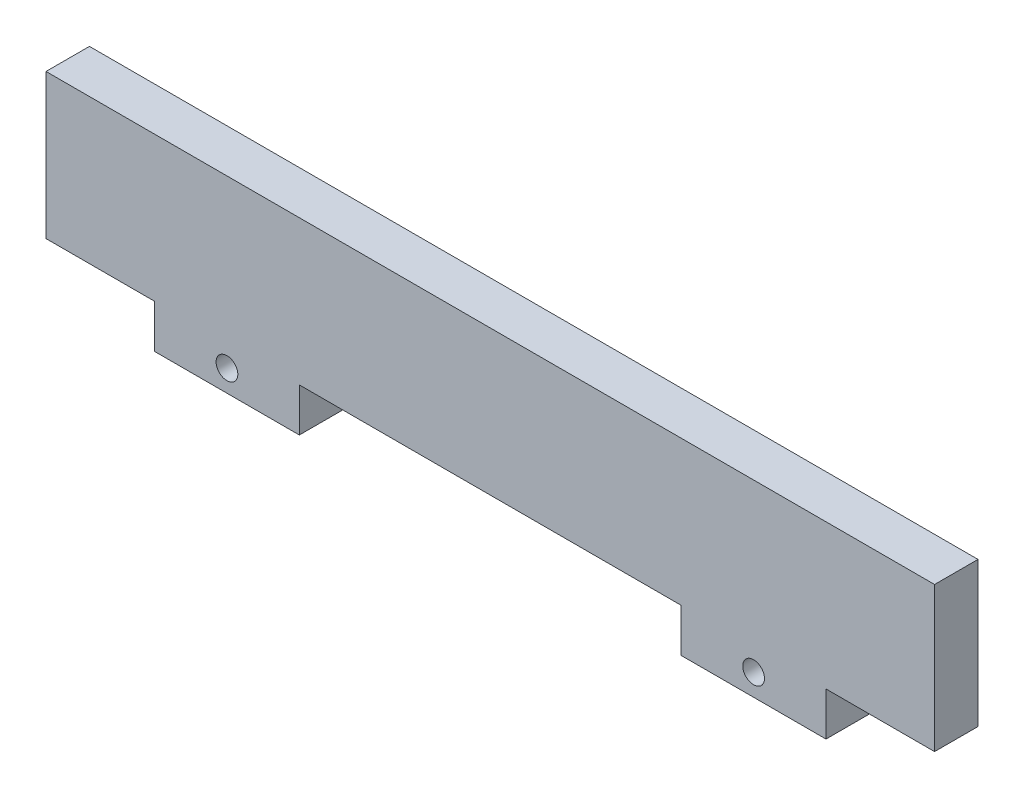
from build123d import *

# Parameters (mm, degrees)
ESQUISSE1_W             = 122.76
ESQUISSE1_H             = 20
BOSS_EXTRU_1_DEPTH      = 6
ESQUISSE2_W             = 20
ESQUISSE2_H             = 6
BOSS_EXTRU_2_DEPTH      = 6
ESQUISSE3_R             = 1.5
ENL_V_MAT_EXTRU_1_DEPTH = 6


with BuildPart() as part:
    # Esquisse1 → Boss.-Extru.1 (new body)
    with BuildSketch(Plane.XY):
        Rectangle(ESQUISSE1_W, ESQUISSE1_H)
    extrude(amount=BOSS_EXTRU_1_DEPTH)

    # Esquisse2 → Boss.-Extru.2 (add)
    with BuildSketch(Plane.XY.offset(6)):
        with Locations((-36.38, -13)):
            Rectangle(ESQUISSE2_W, ESQUISSE2_H)
        with Locations((36.38, -13)):
            Rectangle(ESQUISSE2_W, ESQUISSE2_H)
    extrude(amount=-BOSS_EXTRU_2_DEPTH)

    # Esquisse3 → Enlèv. mat.-Extru.1 (cut)
    with BuildSketch(Plane.XY.offset(6)):
        with Locations((-36.38, -13)):
            Circle(ESQUISSE3_R)
        with Locations((36.38, -13)):
            Circle(ESQUISSE3_R)
    extrude(amount=-ENL_V_MAT_EXTRU_1_DEPTH, mode=Mode.SUBTRACT)


solid = part.part
